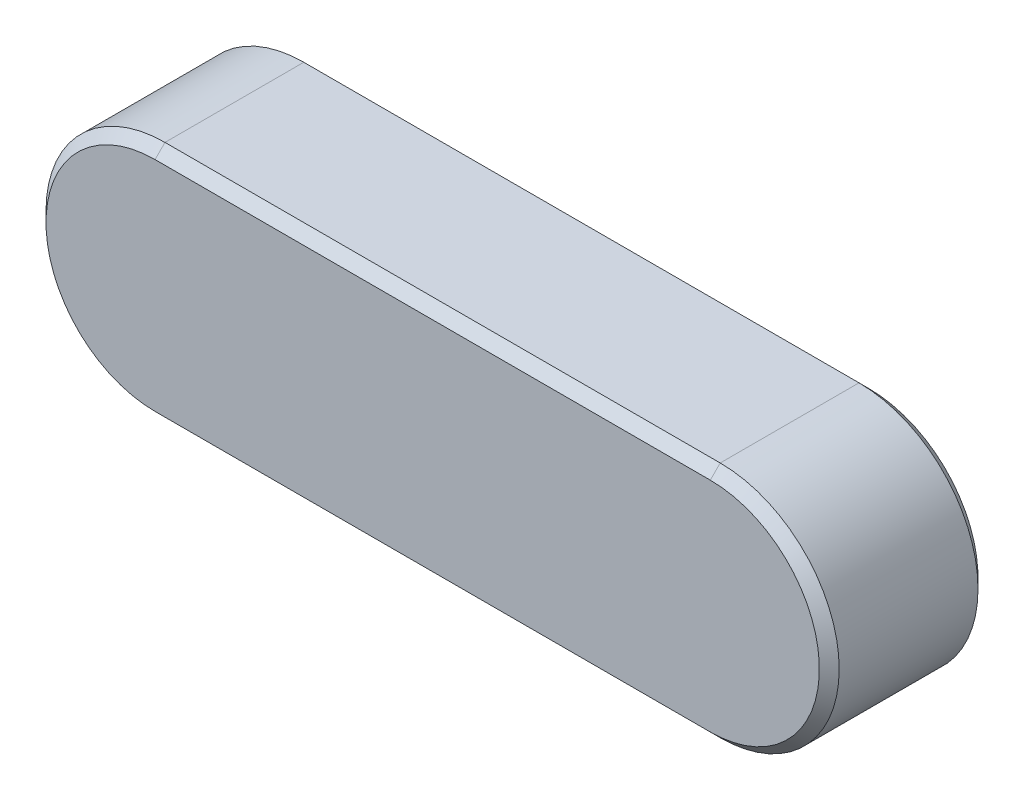
from build123d import *

# Parameters (mm, degrees)
EXTRUDE1_DEPTH = 4
CHAMFER1_SIZE  = 0.25


with BuildPart() as part:
    # Sketch1 → Extrude1 (new body)
    with BuildSketch(Plane.XY):
        with BuildLine():
            Line((0, 3), (-14, 3))
            ThreePointArc((-14, 3), (-17, 0), (-14, -3))
            Line((-14, -3), (0, -3))
            ThreePointArc((0, -3), (3, 0), (0, 3))
        make_face()
    extrude(amount=EXTRUDE1_DEPTH)

    # Chamfer1
    chamfer1_edges = [part.edges().sort_by_distance(p)[0] for p in [
        (-17, 0, 4),
        (-7, -3, 4),
        (3, 0, 4),
        (-7, -3, 0),
        (-17, 0, 0),
        (-7, 3, 0),
        (3, 0, 0),
        (-7, 3, 4),
    ]]
    chamfer(chamfer1_edges, length=CHAMFER1_SIZE)


solid = part.part
